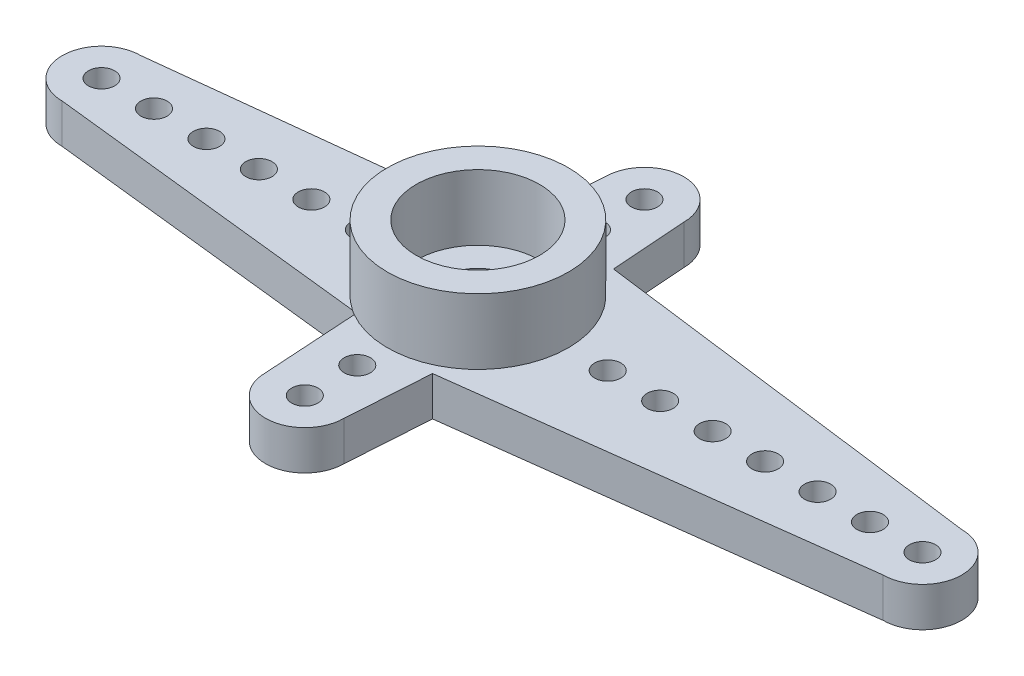
from build123d import *

# Parameters (mm, degrees)
SKETCH1_R           = 0.5
SKETCH1_R_2         = 2.35
BOSS_EXTRUDE1_DEPTH = 1.5
BOSS_EXTRUDE2_START = -0.5
SKETCH6_R           = 2.35
SKETCH6_R_2         = 1.275
BOSS_EXTRUDE2_DEPTH = 0.5
SKETCH6_3_R         = 3.45
SKETCH6_3_R_2       = 2.35
BOSS_EXTRUDE3_DEPTH = 2.5


with BuildPart() as part:
    # Sketch1 → Boss-Extrude1 (new body)
    with BuildSketch(Plane(origin=(0, 0, 0), x_dir=(1, 0, 0), z_dir=(0, 1, 0))):
        with BuildLine():
            ThreePointArc((16.95, -1.5), (18.45, 0), (16.95, 1.5))
            Line((16.95, 1.5), (1.708462071, 3.462274604))
            Line((1.708462071, 3.462274604), (1.5, 6.35))
            ThreePointArc((1.5, 6.35), (0, 7.85), (-1.5, 6.35))
            Line((-1.5, 6.35), (-1.733484834, 2.909271084))
            Line((-1.733484834, 2.909271084), (-14.35, 1.5))
            ThreePointArc((-14.35, 1.5), (-15.85, 0), (-14.35, -1.5))
            Line((-14.35, -1.5), (-1.733484834, -2.890728916))
            Line((-1.733484834, -2.890728916), (-1.5, -6.6))
            ThreePointArc((-1.5, -6.6), (0, -8.1), (1.5, -6.6))
            Line((1.5, -6.6), (1.708462071, -3.437725396))
            Line((1.708462071, -3.437725396), (16.95, -1.5))
        make_face()
        with Locations((0, -6.6)):
            Circle(SKETCH1_R, mode=Mode.SUBTRACT)
        with Locations((0, -4.6)):
            Circle(SKETCH1_R, mode=Mode.SUBTRACT)
        with Locations((-14.35, 0)):
            Circle(SKETCH1_R, mode=Mode.SUBTRACT)
        with Locations((-12.35, 0)):
            Circle(SKETCH1_R, mode=Mode.SUBTRACT)
        with Locations((-10.35, 0)):
            Circle(SKETCH1_R, mode=Mode.SUBTRACT)
        with Locations((-8.35, 0)):
            Circle(SKETCH1_R, mode=Mode.SUBTRACT)
        with Locations((-6.35, 0)):
            Circle(SKETCH1_R, mode=Mode.SUBTRACT)
        with Locations((-4.35, 0)):
            Circle(SKETCH1_R, mode=Mode.SUBTRACT)
        Circle(SKETCH1_R_2, mode=Mode.SUBTRACT)
        with Locations((0, 4.35)):
            Circle(SKETCH1_R, mode=Mode.SUBTRACT)
        with Locations((0, 6.35)):
            Circle(SKETCH1_R, mode=Mode.SUBTRACT)
        with Locations((4.95, 0)):
            Circle(SKETCH1_R, mode=Mode.SUBTRACT)
        with Locations((6.95, 0)):
            Circle(SKETCH1_R, mode=Mode.SUBTRACT)
        with Locations((8.95, 0)):
            Circle(SKETCH1_R, mode=Mode.SUBTRACT)
        with Locations((10.95, 0)):
            Circle(SKETCH1_R, mode=Mode.SUBTRACT)
        with Locations((12.95, 0)):
            Circle(SKETCH1_R, mode=Mode.SUBTRACT)
        with Locations((14.95, 0)):
            Circle(SKETCH1_R, mode=Mode.SUBTRACT)
        with Locations((16.95, 0)):
            Circle(SKETCH1_R, mode=Mode.SUBTRACT)
    extrude(amount=BOSS_EXTRUDE1_DEPTH)

    # Sketch6 → Boss-Extrude2 (add)
    with BuildSketch(Plane(origin=(0, 1.5, 0), x_dir=(1, 0, 0), z_dir=(0, 1, 0)).offset(BOSS_EXTRUDE2_START)):
        Circle(SKETCH6_R)
        Circle(SKETCH6_R_2, mode=Mode.SUBTRACT)
    extrude(amount=BOSS_EXTRUDE2_DEPTH)

    # Sketch6_3 → Boss-Extrude3 (add)
    with BuildSketch(Plane(origin=(0, 1.5, 0), x_dir=(1, 0, 0), z_dir=(0, 1, 0))):
        Circle(SKETCH6_3_R)
        Circle(SKETCH6_3_R_2, mode=Mode.SUBTRACT)
    extrude(amount=BOSS_EXTRUDE3_DEPTH)


solid = part.part
